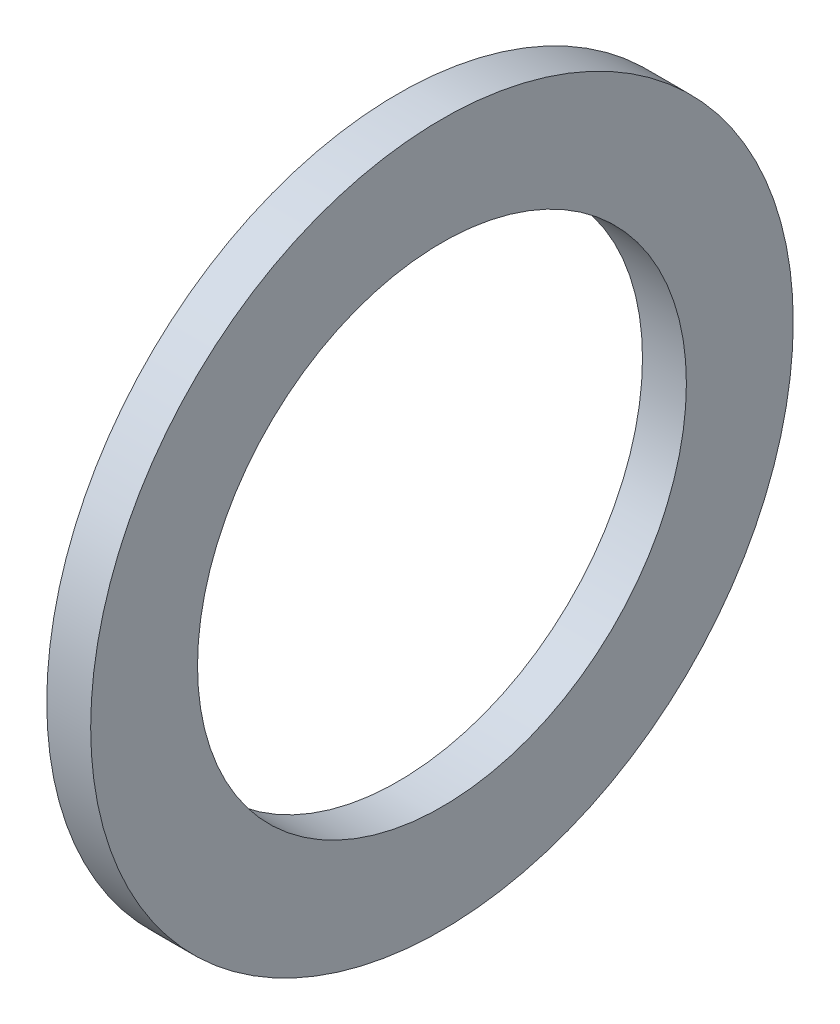
from build123d import *

# Parameters (mm, degrees)
SKETCH1_W = 1.5
SKETCH1_H = 2.433333333
SKETCH2_W = 1.5
SKETCH2_H = 1.216666667


with BuildPart() as part:
    # Sketch1 → Revolve1 (revolve)
    with BuildSketch(Plane.XY):
        with Locations((592.390416263, 464.377595661)):
            Rectangle(SKETCH1_W, SKETCH1_H)
    revolve(axis=Axis((593.140416263, 453.594262328, 0), (-1, 0, 0)))

    # Sketch2 → Revolve2 (revolve)
    with BuildSketch(Plane.XY):
        with Locations((592.390416263, 462.552595662)):
            Rectangle(SKETCH2_W, SKETCH2_H)
    revolve(axis=Axis((593.140416263, 453.594262328, 0), (-1, 0, 0)))


solid = part.part
